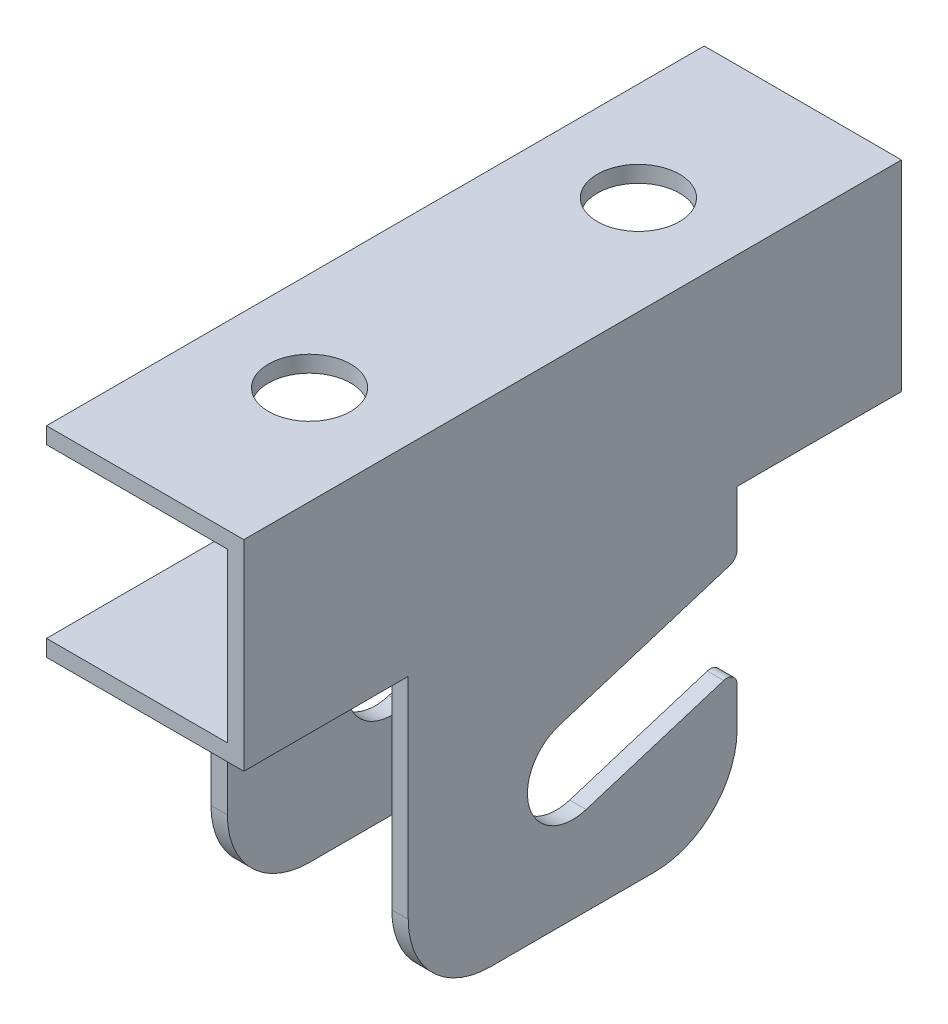
from build123d import *

# Parameters (mm, degrees)
BOSS_EXTRUDE1_DEPTH     = 50.8
SKETCH4_W               = 25.4
SKETCH4_H               = 45.212
CUT_EXTRUDE1_DEPTH      = 1
CUT_EXTRUDE1_DEPTH_BACK = 31.48
CUT_EXTRUDE4_DEPTH      = 1
CUT_EXTRUDE4_DEPTH_BACK = 31.48
SKETCH8_R               = 6.35
BOLT_HOLES_DEPTH        = 1
BOLT_HOLES_DEPTH_BACK   = 77.2
FILLET3_R               = 12.7
FILLET4_R               = 1.5875


with BuildPart() as part:
    # Sketch1 → Boss-Extrude1 (new body, symmetric)
    with BuildSketch(Plane.XY):
        Polygon((0, 76.2), (30.48, 76.2), (30.48, 73.66), (30.48, 47.752), (30.48, 0), (27.94, 0), (27.94, 45.212), (2.54, 45.212), (2.54, 0), (0, 0), (0, 47.752), (27.94, 47.752), (27.94, 73.66), (0, 73.66), align=None)
    extrude(amount=BOSS_EXTRUDE1_DEPTH, both=True)

    # Sketch4 → Cut-Extrude1 (cut, two sides)
    with BuildSketch(Plane(origin=(30.48, 0, 0), x_dir=(0, 0, -1), z_dir=(1, 0, 0))) as cut_extrude1_sk:
        with Locations((-38.1, 22.606)):
            Rectangle(SKETCH4_W, SKETCH4_H)
        with Locations((38.1, 22.606)):
            Rectangle(SKETCH4_W, SKETCH4_H)
    extrude(amount=CUT_EXTRUDE1_DEPTH, mode=Mode.SUBTRACT)
    extrude(cut_extrude1_sk.sketch, amount=-CUT_EXTRUDE1_DEPTH_BACK, mode=Mode.SUBTRACT)

    # Sketch7 → Cut-Extrude4 (cut, two sides)
    with BuildSketch(Plane(origin=(30.48, 0, 0), x_dir=(0, 0, -1), z_dir=(1, 0, 0))) as cut_extrude4_sk:
        with BuildLine():
            Line((-2.079997498, 26.98812083), (25.4, 35.56))
            Line((25.4, 35.56), (25.4, 20.926124507))
            Line((25.4, 20.926124507), (2.079997498, 13.65187917))
            ThreePointArc((2.079997498, 13.65187917), (-6.66812083, 18.240002502), (-2.079997498, 26.98812083))
        make_face()
    extrude(amount=CUT_EXTRUDE4_DEPTH, mode=Mode.SUBTRACT)
    extrude(cut_extrude4_sk.sketch, amount=-CUT_EXTRUDE4_DEPTH_BACK, mode=Mode.SUBTRACT)

    # Sketch8 → BOLT HOLES (cut, two sides)
    with BuildSketch(Plane(origin=(0, 76.2, 0), x_dir=(1, 0, 0), z_dir=(0, 1, 0))) as bolt_holes_sk:
        with Locations((15.24, -25.4)):
            Circle(SKETCH8_R)
        with Locations((15.24, 25.4)):
            Circle(SKETCH8_R)
    extrude(amount=BOLT_HOLES_DEPTH, mode=Mode.SUBTRACT)
    extrude(bolt_holes_sk.sketch, amount=-BOLT_HOLES_DEPTH_BACK, mode=Mode.SUBTRACT)

    # Fillet3
    fillet3_edges = [part.edges().sort_by_distance(p)[0] for p in [
        (1.27, 0, 25.4),
        (29.21, 0, 25.4),
        (1.27, 0, -25.4),
        (29.21, 0, -25.4),
    ]]
    fillet(fillet3_edges, radius=FILLET3_R)

    # Fillet4
    fillet4_edges = [part.edges().sort_by_distance(p)[0] for p in [
        (1.27, 35.56, -25.4),
        (29.21, 35.56, -25.4),
        (1.27, 20.926124507, -25.4),
        (29.21, 20.926124507, -25.4),
    ]]
    fillet(fillet4_edges, radius=FILLET4_R)


solid = part.part
